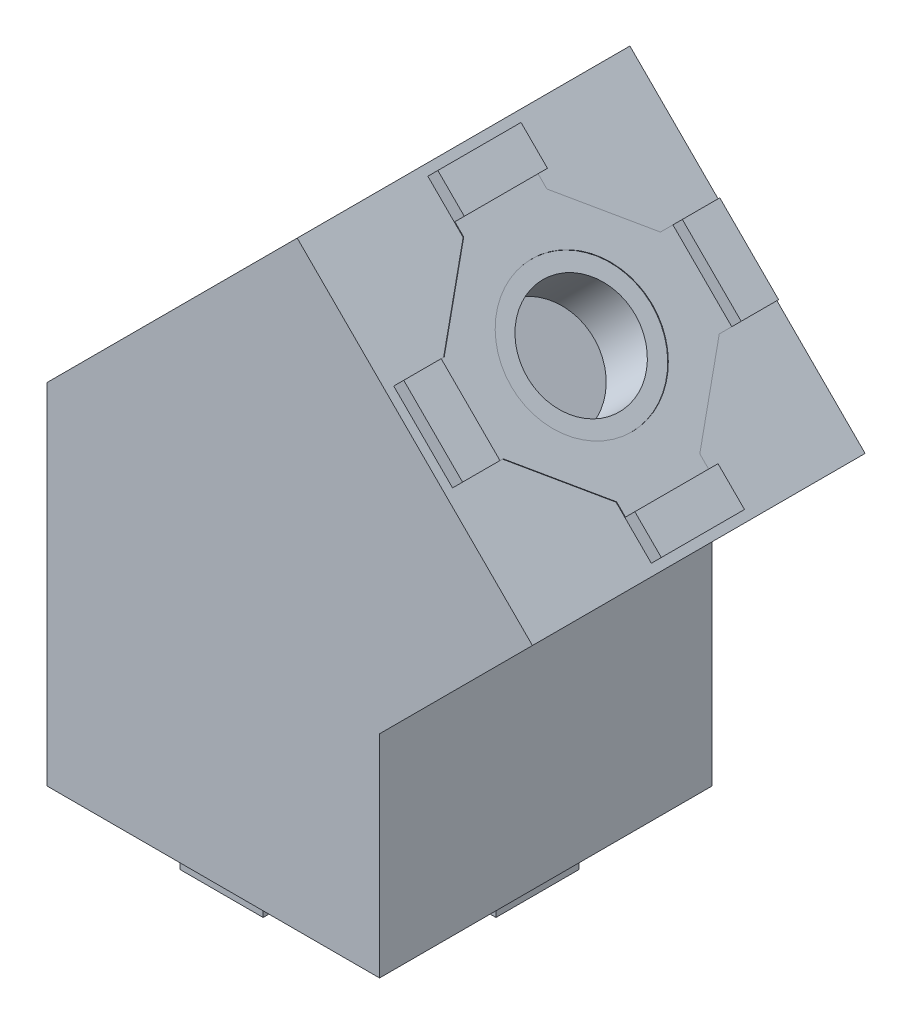
from build123d import *

# Parameters (mm, degrees)
SKETCH_2_W           = 40
SKETCH_2_H           = 40
EXTRUDE_1_DEPTH      = 42
CUT_EXTRUDE_1_DEPTH  = 42
CUT_EXTRUDE_START    = 7
SKETCH_5_W           = 35.4
SKETCH_5_H           = 30.8
CUT_EXTRUDE_2_DEPTH  = 42
EXTRUDE_2_DEPTH      = 40
CUT_EXTRUDE_3_REACH  = 81.267
CUT_EXTRUDE_START_2  = -7
SKETCH_7_W           = 31
SKETCH_7_H           = 35.5
CUT_EXTRUDE_4_DEPTH  = 1
CUT_EXTRUDE_5_DEPTH  = 1
SKETCH_14_W          = 31
SKETCH_14_H          = 34.585786438
CUT_EXTRUDE_7_DEPTH  = 34.5
SKETCH_15_R          = 6.5
CUT_EXTRUDE_8_DEPTH  = 10
SKETCH_16_R          = 6.5
CUT_EXTRUDE_9_DEPTH  = 10
SKETCH_17_R          = 8.5
CUT_EXTRUDE_10_DEPTH = 3.5
SKETCH_19_W          = 28
SKETCH_19_H          = 28
SKETCH_19_R          = 6.5
EXTRUDE_3_DEPTH      = 2
SKETCH_20_R          = 8.5
CUT_EXTRUDE_11_DEPTH = 3.5
SKETCH_21_W          = 28
SKETCH_21_H          = 28
SKETCH_21_R          = 6.5
EXTRUDE_4_DEPTH      = 2
EXTRUDE_START        = 0.1
EXTRUDE_5_DEPTH      = 32.6
SKETCH_23_R          = 8.5
EXTRUDE_6_DEPTH      = 1.6
SKETCH_24_W          = 10
SKETCH_24_H          = 4.5
SKETCH_24_W_2        = 4.5
SKETCH_24_H_2        = 10
EXTRUDE_7_DEPTH      = 1.6
SKETCH_25_R          = 8.5
EXTRUDE_8_DEPTH      = 1.6
SKETCH_26_W          = 10
SKETCH_26_H          = 4.5
SKETCH_26_W_2        = 4.5
SKETCH_26_H_2        = 10
EXTRUDE_9_DEPTH      = 1.6


with BuildPart() as part:
    # Эскиз2 → Бобышка-Вытянуть1 (new body)
    with BuildSketch(Plane(origin=(0, 0, 0), x_dir=(1, 0, 0), z_dir=(0, 1, 0))):
        Rectangle(SKETCH_2_W, SKETCH_2_H)
    extrude(amount=EXTRUDE_1_DEPTH)

    # Эскиз4 → Вырез-Вытянуть1 (cut)
    with BuildSketch(Plane.XY.offset(20)):
        Polygon((20, 42), (-20, 42), (20, 25.431457505), align=None)
    extrude(amount=-CUT_EXTRUDE_1_DEPTH, mode=Mode.SUBTRACT)

    # Эскиз5 → Вырез-Вытянуть2 (cut)
    with BuildSketch(Plane(origin=(0, 0, 0), x_dir=(1, 0, 0), z_dir=(0, 1, 0)).offset(CUT_EXTRUDE_START)):
        with Locations((-2.3, 0)):
            Rectangle(SKETCH_5_W, SKETCH_5_H)
    extrude(amount=CUT_EXTRUDE_2_DEPTH, mode=Mode.SUBTRACT)

    # Эскиз6 → Бобышка-Вытянуть2 (add)
    with BuildSketch(Plane.XY.offset(20)):
        Polygon((20, 25.431457505), (38.384776311, 43.816233816), (10.100505063, 72.100505063), (-20, 42), align=None)
    extrude(amount=-EXTRUDE_2_DEPTH)

    # Вырез-Вытянуть3: up to this plane
    cut_extrude_3_end = Plane(origin=(20, 25.431457505, -94.744779783), z_dir=(0.382683432, 0.923879533, 0))
    # Эскиз7 → Вырез-Вытянуть3 (cut, up to the surface)
    with BuildSketch(Plane(origin=(41.100505063, 41.100505063, 0), x_dir=(0, 0, -1), z_dir=(0.707106781, 0.707106781, 0)).offset(CUT_EXTRUDE_START_2), mode=Mode.PRIVATE) as cut_extrude_3_sk1:
        with Locations((0, 26.090620434)):
            Rectangle(SKETCH_7_W, SKETCH_7_H)
    cut_extrude_3_tool1 = split(extrude(cut_extrude_3_sk1.sketch, amount=-CUT_EXTRUDE_3_REACH, mode=Mode.PRIVATE), bisect_by=cut_extrude_3_end, keep=Keep.BOTH, mode=Mode.PRIVATE)
    add(cut_extrude_3_tool1.solids().sort_by_distance((17.701903, 54.599612, 0))[0], mode=Mode.SUBTRACT)

    # Эскиз8 → Вырез-Вытянуть4 (cut)
    with BuildSketch(Plane.ZY.offset(20)):
        Polygon((-16.4, 42), (-16.4, 4), (16.4, 4), (16.4, 42), (15.4, 42), (15.4, 7), (-15.4, 7), (-15.4, 42), align=None)
    extrude(amount=-CUT_EXTRUDE_4_DEPTH, mode=Mode.SUBTRACT)

    # Эскиз12 → Вырез-Вытянуть5 (cut)
    with BuildSketch(Plane(origin=(-31, 31, 0), x_dir=(0, 0, 1), z_dir=(-0.707106781, 0.707106781, 0))):
        Polygon((-16.4, 15.556349186), (-16.4, 54.124891681), (16.4, 54.124891681), (16.4, 15.556349186), (15.5, 15.556349186), (15.5, 51.124891681), (-15.5, 51.124891681), (-15.5, 15.556349186), align=None)
    extrude(amount=-CUT_EXTRUDE_5_DEPTH, mode=Mode.SUBTRACT)

    # Эскиз14 → Вырез-Вытянуть7 (cut)
    with BuildSketch(Plane.ZY.offset(19)):
        with Locations((0, 24.292893219)):
            Rectangle(SKETCH_14_W, SKETCH_14_H)
    extrude(amount=-CUT_EXTRUDE_7_DEPTH, mode=Mode.SUBTRACT)

    # Эскиз15 → Вырез-Вытянуть8 (cut)
    with BuildSketch(Plane(origin=(41.100505063, 41.100505063, 0), x_dir=(0, 0, -1), z_dir=(0.707106781, 0.707106781, 0))):
        with Locations(Location((0, 23.840620434, 0), (0, 0, 90))):  # turned: the seam where the file's is
            Circle(SKETCH_15_R)
    extrude(amount=-CUT_EXTRUDE_8_DEPTH, mode=Mode.SUBTRACT)

    # Эскиз16 → Вырез-Вытянуть9 (cut)
    with BuildSketch(Plane.XZ):
        with Locations(Location((0, 0, 0), (0, 0, 270))):  # turned: the seam where the file's is
            Circle(SKETCH_16_R)
    extrude(amount=-CUT_EXTRUDE_9_DEPTH, mode=Mode.SUBTRACT)

    # Эскиз17 → Вырез-Вытянуть10 (cut)
    with BuildSketch(Plane(origin=(41.100505063, 41.100505063, 0), x_dir=(0, 0, -1), z_dir=(0.707106781, 0.707106781, 0))):
        Polygon((0, 42.840620434), (-5, 42.840620434), (-5, 36.840620434), (-13, 28.840620434), (-19, 28.840620434), (-19, 23.840620434), (-19, 18.840620434), (-13, 18.840620434), (-5, 10.840620434), (-5, 4.840620434), (5, 4.840620434), (5, 10.840620434), (13, 18.840620434), (19, 18.840620434), (19, 28.840620434), (13, 28.840620434), (5, 36.840620434), (5, 42.840620434), align=None)
        with Locations(Location((0, 23.840620434, 0), (0, 0, 90))):  # turned: the seam where the file's is
            Circle(SKETCH_17_R, mode=Mode.SUBTRACT)
    extrude(amount=-CUT_EXTRUDE_10_DEPTH, mode=Mode.SUBTRACT)

    # Эскиз19 → Бобышка-Вытянуть3 (add)
    with BuildSketch(Plane(origin=(38.625631329, 38.625631329, 0), x_dir=(0, 0, -1), z_dir=(0.707106781, 0.707106781, 0))):
        with Locations((0, 23.840620434)):
            Rectangle(SKETCH_19_W, SKETCH_19_H)
        with Locations(Location((0, 23.840620434, 0), (0, 0, 90))):  # turned: the seam where the file's is
            Circle(SKETCH_19_R, mode=Mode.SUBTRACT)
    extrude(amount=EXTRUDE_3_DEPTH)

    # Эскиз20 → Вырез-Вытянуть11 (cut)
    with BuildSketch(Plane.XZ):
        Polygon((0, 19), (-5, 19), (-5, 13), (-13, 5), (-19, 5), (-19, 0), (-19, -5), (-13, -5), (-5, -13), (-5, -19), (5, -19), (5, -13), (13, -5), (19, -5), (19, 5), (13, 5), (5, 13), (5, 19), align=None)
        with Locations(Location((0, 0, 0), (0, 0, 270))):  # turned: the seam where the file's is
            Circle(SKETCH_20_R, mode=Mode.SUBTRACT)
    extrude(amount=-CUT_EXTRUDE_11_DEPTH, mode=Mode.SUBTRACT)

    # Эскиз21 → Бобышка-Вытянуть4 (add)
    with BuildSketch(Plane.XZ.offset(-3.5)):
        Rectangle(SKETCH_21_W, SKETCH_21_H)
        with Locations(Location((0, 0, 0), (0, 0, 270))):  # turned: the seam where the file's is
            Circle(SKETCH_21_R, mode=Mode.SUBTRACT)
    extrude(amount=EXTRUDE_4_DEPTH)

    # Эскиз22 → Бобышка-Вытянуть5 (add)
    with BuildSketch(Plane(origin=(0, 0, 16.4), x_dir=(-1, 0, 0), z_dir=(0, 0, -1)).offset(EXTRUDE_START)):
        Polygon((-7.908474042, 68.494260479), (-7.201367261, 69.201367261), (20, 42), (20, 4.1), (19, 4.1), (19, 41.585786438), align=None)
    extrude(amount=EXTRUDE_5_DEPTH)

    # Эскиз23 → Бобышка-Вытянуть6 (add)
    with BuildSketch(Plane(origin=(40.039844892, 40.039844892, 0), x_dir=(0, 0, -1), z_dir=(0.707106781, 0.707106781, 0))):
        Polygon((-19, 18.840620434), (-19, 28.840620434), (-13, 28.840620434), (-5, 36.840620434), (-5, 42.840620434), (5, 42.840620434), (5, 36.840620434), (13, 28.840620434), (19, 28.840620434), (19, 18.840620434), (13, 18.840620434), (5, 10.840620434), (5, 4.840620434), (-5, 4.840620434), (-5, 10.840620434), (-13, 18.840620434), align=None)
        with Locations(Location((0, 23.840620434, 0), (0, 0, 270))):  # turned: the seam where the file's is
            Circle(SKETCH_23_R, mode=Mode.SUBTRACT)
    extrude(amount=EXTRUDE_6_DEPTH)

    # Эскиз24 → Бобышка-Вытянуть7 (add)
    with BuildSketch(Plane(origin=(41.171215742, 41.171215742, 0), x_dir=(0, 0, -1), z_dir=(0.707106781, 0.707106781, 0))):
        with Locations((0, 40.590620434)):
            Rectangle(SKETCH_24_W, SKETCH_24_H)
        with Locations((-16.75, 23.840620434)):
            Rectangle(SKETCH_24_W_2, SKETCH_24_H_2)
        with Locations((0, 7.090620434)):
            Rectangle(SKETCH_24_W, SKETCH_24_H)
        with Locations((16.75, 23.840620434)):
            Rectangle(SKETCH_24_W_2, SKETCH_24_H_2)
    extrude(amount=EXTRUDE_7_DEPTH)

    # Эскиз25 → Бобышка-Вытянуть8 (add)
    with BuildSketch(Plane.XZ.offset(-1.5)):
        Polygon((-5, 13), (-5, 19), (5, 19), (5, 13), (13, 5), (19, 5), (19, -5), (13, -5), (5, -13), (5, -19), (-5, -19), (-5, -13), (-13, -5), (-19, -5), (-19, 5), (-13, 5), align=None)
        with Locations(Location((0, 0, 0), (0, 0, 90))):  # turned: the seam where the file's is
            Circle(SKETCH_25_R, mode=Mode.SUBTRACT)
    extrude(amount=EXTRUDE_8_DEPTH)

    # Эскиз26 → Бобышка-Вытянуть9 (add)
    with BuildSketch(Plane.XZ.offset(0.1)):
        with Locations((0, 16.75)):
            Rectangle(SKETCH_26_W, SKETCH_26_H)
        with Locations((16.75, 0)):
            Rectangle(SKETCH_26_W_2, SKETCH_26_H_2)
        with Locations((0, -16.75)):
            Rectangle(SKETCH_26_W, SKETCH_26_H)
        with Locations((-16.75, 0)):
            Rectangle(SKETCH_26_W_2, SKETCH_26_H_2)
    extrude(amount=EXTRUDE_9_DEPTH)


solid = part.part
